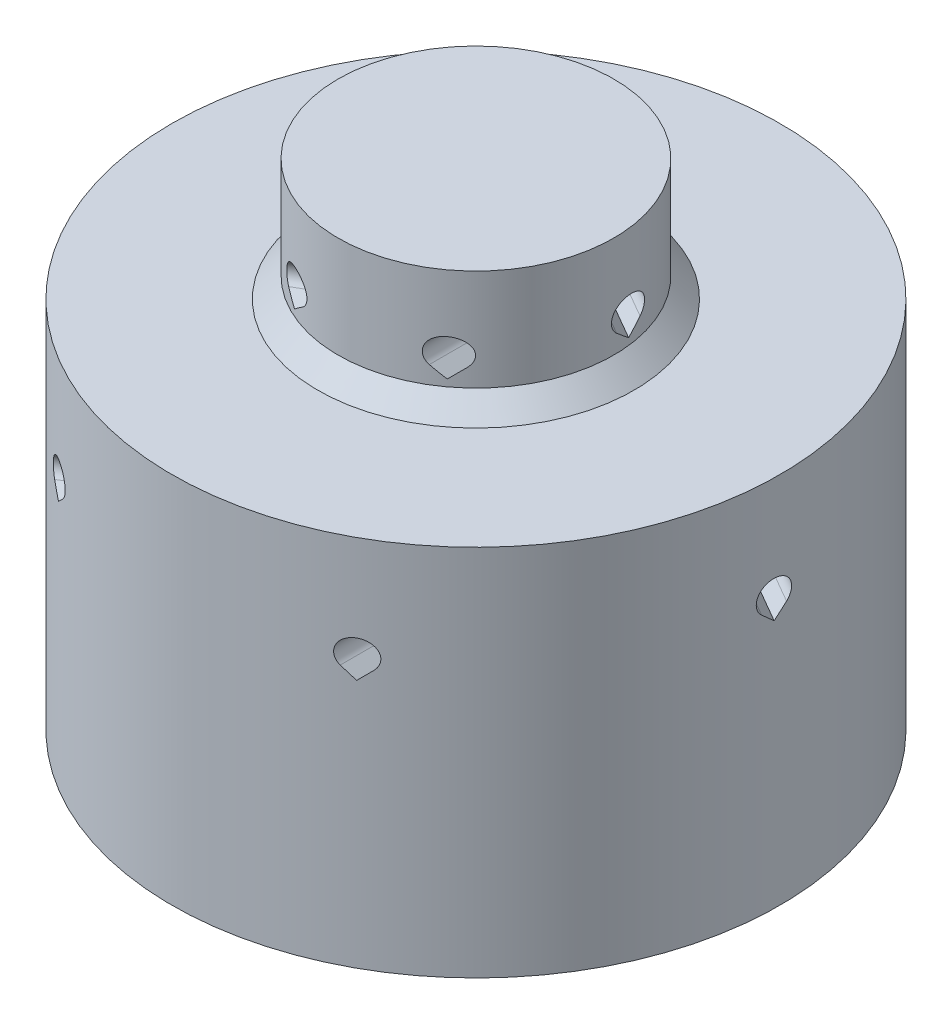
from build123d import *

# Parameters (mm, degrees)
SKETCH3_W          = 4.445
SKETCH3_H          = 1.5875
CUT_EXTRUDE1_DEPTH = 29.136842118
CIRPATTERN1_COUNT  = 6
CUT_EXTRUDE2_DEPTH = 29.136842118
CIRPATTERN2_COUNT  = 6


with BuildPart() as part:
    # Sketch1 → Revolve1 (revolve)
    with BuildSketch(Plane.XY):
        Polygon((-5.3975, 0), (-5.3975, -3.96875), (-6.19125, -4.7625), (-11.90625, -4.7625), (-11.90625, -7.1755), (-6.35, -7.1755), (-6.35, -7.9375), (-4.60375, -7.9375), (-4.60375, -13.346282015), (-3.33375, -14.616282015), (-3.33375, -16.8275), (-2.54, -16.8275), (-2.54, -14.2875), (-3.81, -13.0175), (-3.81, -1.5875), (-4.445, -1.5875), (-4.445, 0), align=None)
    revolve(axis=Axis((0, -1.5875, 0), (0, -1, 0)))

    # Sketch2 → Revolve2 (revolve)
    with BuildSketch(Plane.XY):
        Polygon((-6.35, -7.9375), (-6.35, -14.2875), (-4.445, -16.1925), (-4.445, -22.5425), (-6.35, -22.5425), (-6.35, -19.3675), (-7.3152, -19.3675), (-7.3152, -17.3863), (-10.3886, -17.3863), (-10.3886, -19.3675), (-11.90625, -19.3675), (-11.90625, -7.1755), (-6.35, -7.1755), align=None)
    revolve(axis=Axis((0, -1.5875, 0), (0, -1, 0)))

    # Sketch3 → Revolve3 (revolve)
    with BuildSketch(Plane.XY):
        with Locations((-2.2225, -0.79375)):
            Rectangle(SKETCH3_W, SKETCH3_H)
    revolve(axis=Axis((0, -1.5875, 0), (0, 1, 0)))

    # Sketch8 → Cut-Extrude1 (cut, through all)
    with BuildSketch(Plane.XY):
        with BuildLine():
            Line((-3.2146875, -3.699399011), (-3.635637006, -3.278449506))
            ThreePointArc((-3.635637006, -3.278449506), (-3.2146875, -2.2621875), (-2.793737994, -3.278449506))
            Line((-2.793737994, -3.278449506), (-3.2146875, -3.699399011))
        make_face()
    cut_extrude1 = extrude(amount=-CUT_EXTRUDE1_DEPTH, mode=Mode.SUBTRACT)

    # CirPattern1: Cut-Extrude1 ×6 about axis
    cirpattern1_axis = Axis((0, 42.935, 0), (0, -1, 0))
    for i in range(1, CIRPATTERN1_COUNT):
        add(cut_extrude1.rotate(cirpattern1_axis, i * 360 / CIRPATTERN1_COUNT), mode=Mode.SUBTRACT)

    # Sketch9 → Cut-Extrude2 (cut, through all)
    with BuildSketch(Plane.XY):
        with BuildLine():
            Line((-5.7546875, -9.604899011), (-6.175637006, -9.183949506))
            ThreePointArc((-6.175637006, -9.183949506), (-5.7546875, -8.1676875), (-5.333737994, -9.183949506))
            Line((-5.333737994, -9.183949506), (-5.7546875, -9.604899011))
        make_face()
    cut_extrude2 = extrude(amount=-CUT_EXTRUDE2_DEPTH, mode=Mode.SUBTRACT)

    # CirPattern2: Cut-Extrude2 ×6 about axis
    cirpattern2_axis = Axis((0, 42.935, 0), (0, -1, 0))
    for i in range(1, CIRPATTERN2_COUNT):
        add(cut_extrude2.rotate(cirpattern2_axis, i * 360 / CIRPATTERN2_COUNT), mode=Mode.SUBTRACT)


solid = part.part
